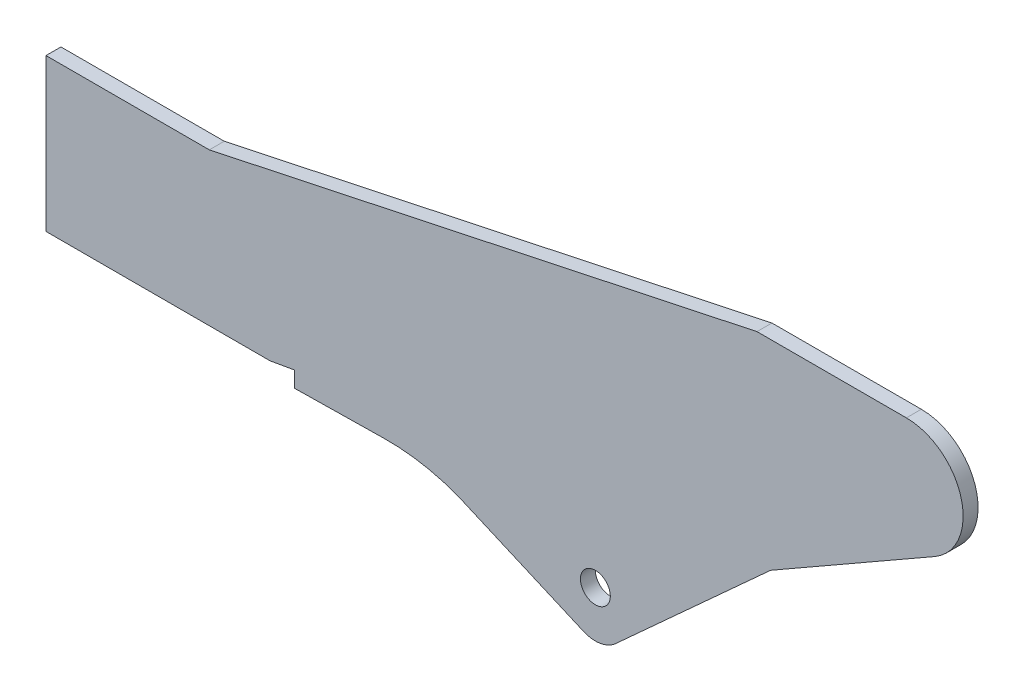
from build123d import *

# Parameters (mm, degrees)
SKETCH2_R           = 15
BOSS_EXTRUDE1_DEPTH = 7.5


with BuildPart() as part:
    # Sketch2 → Boss-Extrude1 (new body, symmetric)
    with BuildSketch(Plane.XY):
        with BuildLine():
            Line((0, 0), (164, 0))
            Line((164, 0), (714, 116.906108919))
            Line((714, 116.906108919), (864, 116.906108919))
            ThreePointArc((864, 116.906108919), (919.084102522, 74.560174885), (892.323020072, 10.440903632))
            Line((892.323020072, 10.440903632), (727.653990867, -83.846064196))
            Line((727.653990867, -83.846064196), (571.872200418, -225.540335787))
            ThreePointArc((571.872200418, -225.540335787), (556.597798177, -232.94262163), (539.751135216, -230.87111334))
            Line((539.751135216, -230.87111334), (413.142119809, -175.969772575))
            ThreePointArc((413.142119809, -175.969772575), (376.982520463, -166.120087872), (339.620193825, -163.189309492))
            Line((339.620193825, -163.189309492), (249.620193825, -164.588795558))
            Line((249.620193825, -164.588795558), (249.620193825, -148.658795558))
            Line((249.620193825, -148.658795558), (225, -153))
            Line((225, -153), (0, -153))
            Line((0, -153), (0, 0))
        make_face()
        with Locations((551.686209295, -186.833379926)):
            Circle(SKETCH2_R, mode=Mode.SUBTRACT)
    extrude(amount=BOSS_EXTRUDE1_DEPTH, both=True)


solid = part.part
